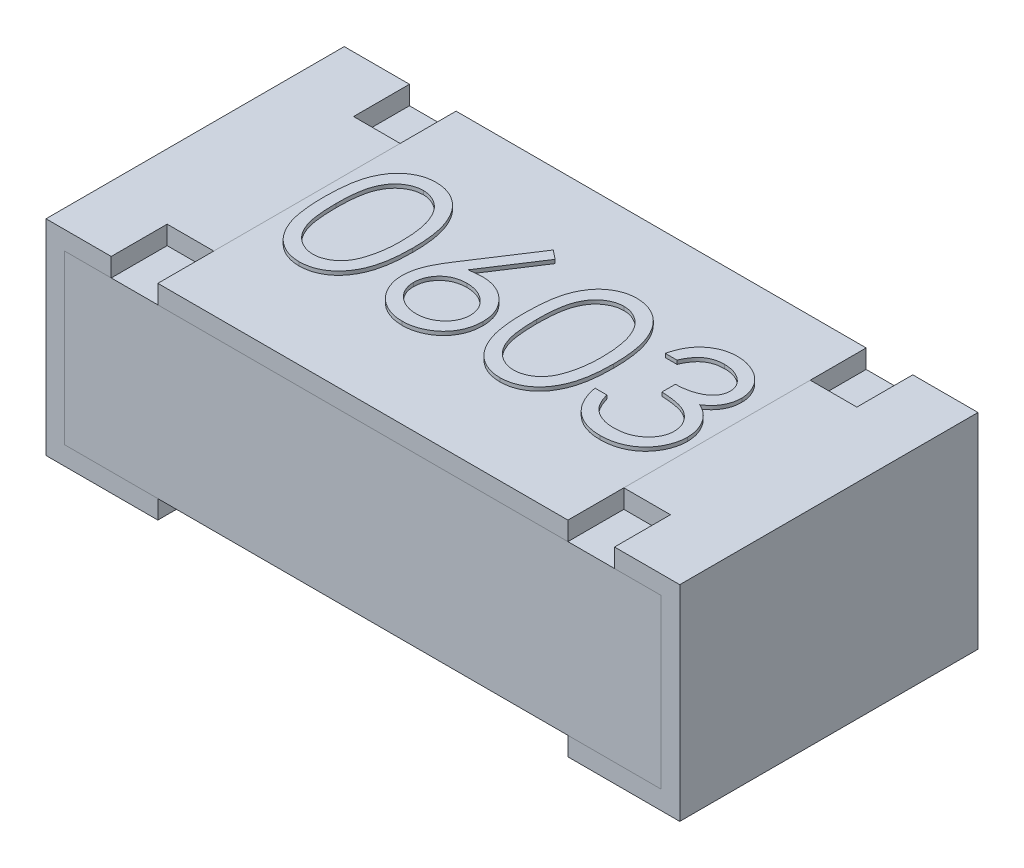
from build123d import *

# Parameters (mm, degrees)
CROQUIS1_W          = 1.6
CROQUIS1_H          = 0.8
EXTRUIR1_DEPTH      = 0.5
CROQUIS2_W          = 1.6
CROQUIS2_H          = 0.05
EXTRUIR2_DEPTH      = 2.236931688
CROQUIS4_W          = 0.8
CROQUIS4_H          = 0.05
EXTRUIR3_DEPTH      = 1.1
CROQUIS5_W          = 0.125
CROQUIS5_H          = 0.15
EXTRUIR4_DEPTH      = 0.05
BOSS_EXTRUDE1_DEPTH = 0.01


with BuildPart() as part:
    # Croquis1 → Extruir1 (new body)
    with BuildSketch(Plane(origin=(0, 0, 0), x_dir=(1, 0, 0), z_dir=(0, 1, 0))):
        Rectangle(CROQUIS1_W, CROQUIS1_H)
    extrude(amount=EXTRUIR1_DEPTH)

    # Croquis2 → Extruir2 (cut, through all)
    with BuildSketch(Plane.XY.offset(0.4)):
        with Locations((0, 0.025)):
            Rectangle(CROQUIS2_W, CROQUIS2_H)
    extrude(amount=-EXTRUIR2_DEPTH, mode=Mode.SUBTRACT)


with BuildPart() as body_2:
    # Barrer1: sweep along a path in Croquis3
    with BuildLine(Plane.XY.offset(0.4)) as barrer1_path:
        Line((-0.55, 0.55), (-0.85, 0.55))
        Line((-0.85, 0.55), (-0.85, 0))
        Line((-0.85, 0), (-0.55, 0))
    # Croquis3D1 → Barrer1 (sweep)
    with BuildSketch(Plane(origin=(-0.55, 0.55, 0.4), x_dir=(0, -0.06237828615518069, -0.9980525784828886), z_dir=(1, 0, 0))):
        Polygon((0, 0), (0.798442063, 0.049902629), (0.801560977, 0), (0.003118914, -0.049902629), align=None)
    sweep(path=barrer1_path.line, transition=Transition.RIGHT)


with BuildPart() as body_3:
    # Simetría1: mirrored copy
    add(body_2.part.mirror(Plane(origin=(0, 0.5, 0.4), x_dir=(0, 0, 1), z_dir=(1, 0, 0))))


with BuildPart() as body_4:
    # Croquis4 → Extruir3 (new body)
    with BuildSketch(Plane(origin=(-0.55, 0, 0), x_dir=(0, 0, -1), z_dir=(1, 0, 0))):
        with Locations((0, 0.525)):
            Rectangle(CROQUIS4_W, CROQUIS4_H)
    extrude(amount=EXTRUIR3_DEPTH)

    # Sketch1 → Boss-Extrude1 (add)
    with BuildSketch(Plane(origin=(0, 0.55, 0), x_dir=(1, 0, 0), z_dir=(0, 1, 0))):
        with BuildLine():
            add(Edge.make_bspline(
                [(-0.517880419, 0.013609611), (-0.517847617, 0.019219349), (-0.517783899, 0.030116348), (-0.517075057, 0.045994812), (-0.515897523, 0.060890841), (-0.514283786, 0.074805147), (-0.512319988, 0.087741324), (-0.509698439, 0.0996648), (-0.506717159, 0.11063076), (-0.503261914, 0.120674965), (-0.499363135, 0.129932735), (-0.495119709, 0.138575256), (-0.49036323, 0.146589449), (-0.485365539, 0.154103228), (-0.479924331, 0.160993597), (-0.474194452, 0.167357864), (-0.467952265, 0.173048939), (-0.461409964, 0.178233569), (-0.454508318, 0.182778516), (-0.447444051, 0.18678179), (-0.44016854, 0.190201777), (-0.432661922, 0.19289082), (-0.424991666, 0.195111905), (-0.41713096, 0.1966308), (-0.409066823, 0.19758649), (-0.40362368, 0.197677857), (-0.400863192, 0.197724194)],
                knots=[0, 0, 0, 0, 1.646270934, 3.197905019, 4.663502075, 6.030701355, 7.308322542, 8.50163776, 9.611534131, 10.641858119, 11.616356847, 12.558055219, 13.465016945, 14.349605745, 15.204443733, 16.039544428, 16.859896111, 17.680448484, 18.487036065, 19.28249412, 20.06191084, 20.843045899, 21.620316918, 22.403196591, 23.190181807, 24, 24, 24, 24], degree=3))
            add(Edge.make_bspline(
                [(-0.400863192, 0.197724194), (-0.398079644, 0.197675412), (-0.392544043, 0.197578401), (-0.384360005, 0.196646007), (-0.376365037, 0.195098895), (-0.368593223, 0.192906797), (-0.360980725, 0.19018723), (-0.353587084, 0.186778518), (-0.346366376, 0.182810631), (-0.339433347, 0.178148243), (-0.332711886, 0.172950016), (-0.326367089, 0.167073749), (-0.320398381, 0.160578777), (-0.31473085, 0.153534591), (-0.30952529, 0.145806082), (-0.304567947, 0.137527671), (-0.300130744, 0.128554585), (-0.295857276, 0.119036538), (-0.292168577, 0.108710172), (-0.288841953, 0.097633696), (-0.286154056, 0.085676277), (-0.283915129, 0.072900653), (-0.282180639, 0.059259904), (-0.280917375, 0.044783273), (-0.280250066, 0.029461234), (-0.280124396, 0.018985449), (-0.280059906, 0.013609611)],
                knots=[0, 0, 0, 0, 0.810914788, 1.612654377, 2.396697861, 3.181598691, 3.963628158, 4.749916497, 5.551656086, 6.361998678, 7.18212741, 8.025565596, 8.878627764, 9.750805457, 10.657531673, 11.591944965, 12.560506719, 13.57287815, 14.630710178, 15.753379473, 16.941251878, 18.199788006, 19.531962791, 20.947069417, 22.433333509, 24, 24, 24, 24], degree=3))
            add(Edge.make_bspline(
                [(-0.280059906, 0.013609611), (-0.280125065, 0.00825722), (-0.280252024, -0.002171695), (-0.280909894, -0.017424793), (-0.282205757, -0.031824597), (-0.283826756, -0.045405644), (-0.286071852, -0.058111405), (-0.288832369, -0.06998585), (-0.291897401, -0.081080257), (-0.295680881, -0.091303739), (-0.299821952, -0.100798911), (-0.304327471, -0.109665626), (-0.309154454, -0.117982255), (-0.314413329, -0.12568223), (-0.32001867, -0.132820095), (-0.326090449, -0.139269858), (-0.332457507, -0.145186925), (-0.339198749, -0.150452088), (-0.346239904, -0.155060568), (-0.353435812, -0.159181953), (-0.36091415, -0.162505223), (-0.368505445, -0.165358727), (-0.376318282, -0.167538772), (-0.384342921, -0.169046157), (-0.392538545, -0.170103342), (-0.398078701, -0.17018399), (-0.400863192, -0.170224524)],
                knots=[0, 0, 0, 0, 1.561518951, 3.042555995, 4.452378317, 5.7783523, 7.031515105, 8.214008947, 9.334062868, 10.386615937, 11.391082383, 12.354592575, 13.286541444, 14.194233754, 15.072674879, 15.931287219, 16.775624067, 17.606195743, 18.42308326, 19.229000347, 20.022332153, 20.807536673, 21.593273796, 22.3848459, 23.188221202, 24, 24, 24, 24], degree=3))
            add(Edge.make_bspline(
                [(-0.400863192, -0.170224524), (-0.403623603, -0.170177889), (-0.409066596, -0.170085932), (-0.417131838, -0.169134559), (-0.424960083, -0.167605009), (-0.432589958, -0.165463348), (-0.440060609, -0.162841865), (-0.447270238, -0.159426496), (-0.454299006, -0.15549309), (-0.461128162, -0.151013547), (-0.467629378, -0.145881379), (-0.473839239, -0.14020495), (-0.479601741, -0.133842609), (-0.48496515, -0.126894817), (-0.490062559, -0.119425493), (-0.494751496, -0.111332655), (-0.499088582, -0.102648394), (-0.503052931, -0.093316603), (-0.506567797, -0.08320111), (-0.509672568, -0.072186193), (-0.512123984, -0.060174629), (-0.514222279, -0.047262892), (-0.515914718, -0.033395499), (-0.51707015, -0.018564921), (-0.517784282, -0.0027804), (-0.517847789, 0.008046577), (-0.517880419, 0.013609611)],
                knots=[0, 0, 0, 0, 0.810891512, 1.598919785, 2.382837074, 3.152667961, 3.926044502, 4.706494248, 5.493654104, 6.291793342, 7.103789334, 7.925228297, 8.761435821, 9.622817696, 10.50288917, 11.416980706, 12.369136599, 13.353924996, 14.394355917, 15.514179734, 16.714354668, 17.994756427, 19.357759367, 20.818452758, 22.365282078, 24, 24, 24, 24], degree=3))
        make_face()
        with BuildLine():
            add(Edge.make_bspline(
                [(-0.486470163, 0.013749835), (-0.486458218, 0.009074965), (-0.486435036, 1.961e-06), (-0.485829416, -0.013182366), (-0.485004393, -0.025479398), (-0.483940263, -0.036904752), (-0.482359968, -0.047419753), (-0.480589289, -0.057096722), (-0.47843448, -0.065884445), (-0.475884978, -0.073843226), (-0.472981069, -0.081108133), (-0.469810482, -0.087868255), (-0.46640441, -0.094203448), (-0.462592495, -0.100056809), (-0.458440989, -0.105447426), (-0.454043663, -0.110470709), (-0.449236404, -0.114950407), (-0.44258603, -0.120323093), (-0.433806383, -0.125875006), (-0.422744337, -0.130709615), (-0.411377492, -0.133747861), (-0.403662367, -0.134134236), (-0.399811509, -0.134327088)],
                knots=[0, 0, 0, 0, 1.459021318, 2.831673884, 4.118529203, 5.306027144, 6.411944654, 7.436330062, 8.375795394, 9.233974572, 10.042671642, 10.816086306, 11.563610507, 12.285937304, 12.993564865, 13.685989202, 14.367179055, 15.041617293, 16.353048772, 17.594441528, 18.799311195, 20, 20, 20, 20], degree=3))
            add(Edge.make_bspline(
                [(-0.399811509, -0.134327088), (-0.395935742, -0.13416731), (-0.38819221, -0.133848084), (-0.37687883, -0.13076821), (-0.365895803, -0.126121256), (-0.357288609, -0.120626506), (-0.350740355, -0.115393673), (-0.346048656, -0.110932208), (-0.341742451, -0.105936621), (-0.337658243, -0.100546692), (-0.333912336, -0.094659443), (-0.330506022, -0.088303186), (-0.327397687, -0.081460268), (-0.325626783, -0.076683294), (-0.324721365, -0.07424095)],
                knots=[0, 0, 0, 0, 1.353760809, 2.704726607, 4.075137775, 5.516104923, 6.260822281, 7.007110065, 7.778089737, 8.566572457, 9.372053459, 10.217411131, 11.088608312, 12, 12, 12, 12], degree=3))
            add(Edge.make_bspline(
                [(-0.324721365, -0.07424095), (-0.323666188, -0.071117976), (-0.321523727, -0.064777), (-0.318762549, -0.054940635), (-0.316588009, -0.044620358), (-0.314631673, -0.033877847), (-0.313296367, -0.022633877), (-0.312221586, -0.010923238), (-0.311588517, 0.001262898), (-0.311510042, 0.009542397), (-0.311470163, 0.013749835)],
                knots=[0, 0, 0, 0, 0.884706709, 1.796334032, 2.740027952, 3.714592787, 4.726048262, 5.777819803, 6.87074269, 8, 8, 8, 8], degree=3))
            add(Edge.make_bspline(
                [(-0.311470163, 0.013749835), (-0.311525182, 0.017956592), (-0.311632811, 0.026185909), (-0.312044209, 0.038237727), (-0.313106567, 0.049684503), (-0.314286479, 0.06057555), (-0.316026201, 0.07085058), (-0.317901981, 0.080595611), (-0.320422103, 0.089689913), (-0.32311408, 0.098275871), (-0.32619512, 0.106255937), (-0.329586693, 0.113667316), (-0.333208869, 0.120545788), (-0.337143093, 0.126872482), (-0.341342661, 0.132675736), (-0.345918416, 0.137839196), (-0.350688854, 0.142522893), (-0.357370572, 0.14786915), (-0.366118001, 0.153320319), (-0.377002566, 0.158336895), (-0.38832963, 0.161217724), (-0.395986976, 0.161623893), (-0.399811509, 0.161826758)],
                knots=[0, 0, 0, 0, 1.31362396, 2.569729283, 3.763502607, 4.902122613, 5.988968491, 7.01645872, 7.998833611, 8.933434873, 9.825090667, 10.667526885, 11.477055099, 12.250526234, 12.991942729, 13.710640831, 14.402115721, 15.076753259, 16.378508321, 17.609869233, 18.806226677, 20, 20, 20, 20], degree=3))
            add(Edge.make_bspline(
                [(-0.399811509, 0.161826758), (-0.403682568, 0.161623613), (-0.411431739, 0.161216954), (-0.422876534, 0.158347629), (-0.433846969, 0.153346332), (-0.442571267, 0.147851095), (-0.449257646, 0.142617264), (-0.453965915, 0.138078618), (-0.458380532, 0.133113993), (-0.462447302, 0.127673801), (-0.46625623, 0.121827264), (-0.469754332, 0.115528388), (-0.472906065, 0.108745252), (-0.475814518, 0.101483608), (-0.478371797, 0.093525514), (-0.480481193, 0.084748614), (-0.482429899, 0.075102425), (-0.483809426, 0.064530474), (-0.485035801, 0.053102259), (-0.485823936, 0.040774527), (-0.486437062, 0.027568089), (-0.486458908, 0.018448173), (-0.486470163, 0.013749835)],
                knots=[0, 0, 0, 0, 1.207732386, 2.417664972, 3.655092373, 4.956220595, 5.625982001, 6.301752483, 6.994047911, 7.697131622, 8.419323945, 9.170223765, 9.943494443, 10.752040957, 11.610060368, 12.549350801, 13.567764191, 14.679664412, 15.874934091, 17.154273443, 18.533957287, 20, 20, 20, 20], degree=3))
        make_face(mode=Mode.SUBTRACT)
        with BuildLine():
            Line((-0.087111189, 0.197724194), (-0.062922487, 0.178723793))
            Line((-0.062922487, 0.178723793), (-0.155400451, 0.037307527))
            add(Edge.make_bspline(
                [(-0.155400451, 0.037307527), (-0.149243424, 0.038288913), (-0.137233445, 0.040203218), (-0.125076855, 0.040519012), (-0.119152455, 0.040672912)],
                knots=[0, 0, 0, 0, 1.025318673, 2, 2, 2, 2], degree=3))
            add(Edge.make_bspline(
                [(-0.119152455, 0.040672912), (-0.115595205, 0.040577301), (-0.108592865, 0.040389093), (-0.098312185, 0.038940708), (-0.088433291, 0.036658197), (-0.07899713, 0.033330971), (-0.069969832, 0.029080736), (-0.061299592, 0.023986849), (-0.053149391, 0.017786281), (-0.045414273, 0.010859785), (-0.038391563, 0.003188087), (-0.032173958, -0.004952047), (-0.026951279, -0.013552135), (-0.022713886, -0.022607822), (-0.019423399, -0.032105148), (-0.017024634, -0.042031962), (-0.015606675, -0.052395109), (-0.015414126, -0.059442926), (-0.015316317, -0.063023002)],
                knots=[0, 0, 0, 0, 1.04369286, 2.054478336, 3.041073146, 4.015093852, 4.984733326, 5.965804835, 6.960378782, 7.985147595, 9.009457201, 10.008161701, 10.986880575, 11.956520048, 12.937015923, 13.931873656, 14.949455224, 16, 16, 16, 16], degree=3))
            add(Edge.make_bspline(
                [(-0.015316317, -0.063023002), (-0.015458627, -0.067920972), (-0.015738661, -0.077559019), (-0.01852904, -0.091596689), (-0.022865005, -0.104969941), (-0.029062758, -0.117465258), (-0.036760996, -0.129065515), (-0.046148755, -0.139344061), (-0.056893104, -0.148511065), (-0.069041784, -0.156176727), (-0.08211608, -0.162437032), (-0.09585128, -0.166933556), (-0.110113995, -0.169701903), (-0.119794455, -0.170048964), (-0.124691317, -0.170224524)],
                knots=[0, 0, 0, 0, 1.031375318, 2.029502543, 3.004789286, 3.987476834, 4.960371455, 5.9300674, 6.912260825, 7.929083631, 8.949397511, 9.960523116, 10.96833055, 12, 12, 12, 12], degree=3))
            add(Edge.make_bspline(
                [(-0.124691317, -0.170224524), (-0.129400987, -0.170071704), (-0.138730019, -0.169768993), (-0.152453298, -0.167072399), (-0.1656396, -0.162701689), (-0.178196538, -0.156680261), (-0.189828599, -0.149074473), (-0.200235163, -0.139918245), (-0.20936434, -0.129407298), (-0.216961802, -0.117543263), (-0.222987676, -0.104794268), (-0.227506668, -0.091500552), (-0.230146292, -0.077710554), (-0.230515148, -0.06836244), (-0.230700932, -0.063654011)],
                knots=[0, 0, 0, 0, 1.012016664, 2.004627821, 2.994792927, 3.992885782, 4.990978636, 5.973936114, 6.964471063, 7.975201453, 8.993600317, 9.990122807, 10.98767138, 12, 12, 12, 12], degree=3))
            add(Edge.make_bspline(
                [(-0.230700932, -0.063654011), (-0.230582788, -0.060049553), (-0.230341559, -0.052689938), (-0.22865722, -0.041543535), (-0.225950741, -0.030138427), (-0.222919716, -0.020463007), (-0.219717155, -0.012536855), (-0.217051901, -0.006146506), (-0.213734501, 0.000429601), (-0.210197163, 0.007416965), (-0.206121476, 0.014635508), (-0.201689911, 0.022205875), (-0.196779946, 0.030007668), (-0.19333793, 0.035302087), (-0.191578336, 0.038008649)],
                knots=[0, 0, 0, 0, 1.173818275, 2.396712641, 3.66331629, 4.989737886, 5.693666774, 6.447286557, 7.243889047, 8.091586357, 8.998013824, 9.943181721, 10.948533338, 12, 12, 12, 12], degree=3))
            Line((-0.191578336, 0.038008649), (-0.087111189, 0.197724194))
        make_face()
        with BuildLine():
            add(Edge.make_bspline(
                [(-0.125742999, 0.004775476), (-0.128409224, 0.004697672), (-0.133617135, 0.004545697), (-0.141257876, 0.003663172), (-0.148489201, 0.002001265), (-0.155406915, -0.000115368), (-0.161881685, -0.003025674), (-0.167960569, -0.006560854), (-0.173667074, -0.010722972), (-0.178941429, -0.015453063), (-0.183723396, -0.020631866), (-0.187841509, -0.026178818), (-0.191393749, -0.031960239), (-0.194281931, -0.038024433), (-0.196530938, -0.044369083), (-0.198157763, -0.050965008), (-0.199063139, -0.057856438), (-0.199213762, -0.062529689), (-0.199290676, -0.064916031)],
                knots=[0, 0, 0, 0, 1.129588631, 2.206414736, 3.251139165, 4.268635594, 5.265702196, 6.250456724, 7.242448911, 8.251968645, 9.246821453, 10.222880186, 11.173611482, 12.116736599, 13.062300278, 14.020270554, 14.989073742, 16, 16, 16, 16], degree=3))
            add(Edge.make_bspline(
                [(-0.199290676, -0.064916031), (-0.19922804, -0.067281028), (-0.199105219, -0.071918437), (-0.197989987, -0.078752355), (-0.196286479, -0.085328846), (-0.19375244, -0.091614006), (-0.190729751, -0.097703638), (-0.186739218, -0.103377166), (-0.18231754, -0.108979174), (-0.177032146, -0.114079321), (-0.17135981, -0.118824983), (-0.16529969, -0.122973008), (-0.158983694, -0.126521626), (-0.152326552, -0.129302736), (-0.145422713, -0.131585164), (-0.138214658, -0.133191312), (-0.130697372, -0.134099365), (-0.125605179, -0.134250184), (-0.123008624, -0.134327088)],
                knots=[0, 0, 0, 0, 0.989467248, 1.94019797, 2.891935182, 3.827694429, 4.772920941, 5.730924762, 6.725747692, 7.756678648, 8.79901574, 9.819492441, 10.826891316, 11.826466727, 12.835195252, 13.867842842, 14.912794438, 16, 16, 16, 16], degree=3))
            add(Edge.make_bspline(
                [(-0.123008624, -0.134327088), (-0.120412075, -0.134250178), (-0.115319889, -0.134099347), (-0.107802543, -0.13319138), (-0.100594711, -0.131584915), (-0.09369006, -0.129303638), (-0.087035917, -0.126518277), (-0.080725445, -0.122995085), (-0.074722636, -0.118799473), (-0.069046576, -0.114087431), (-0.063783182, -0.108950145), (-0.059255454, -0.103427173), (-0.055387131, -0.097657784), (-0.052243712, -0.091637995), (-0.049737583, -0.085325046), (-0.048025436, -0.078753374), (-0.046912507, -0.071918171), (-0.046789371, -0.067280938), (-0.046726573, -0.064916031)],
                knots=[0, 0, 0, 0, 1.087397944, 2.132534446, 3.165364764, 4.174271784, 5.174024072, 6.181601208, 7.194203697, 8.236725232, 9.267838612, 10.269026844, 11.221737037, 12.171628256, 13.107553087, 14.05945871, 15.010357665, 16, 16, 16, 16], degree=3))
            add(Edge.make_bspline(
                [(-0.046726573, -0.064916031), (-0.046781602, -0.062526575), (-0.046889607, -0.057836852), (-0.048111202, -0.05096809), (-0.049805439, -0.04433557), (-0.052363742, -0.037980975), (-0.055687397, -0.031929382), (-0.059735738, -0.026150222), (-0.064418995, -0.020599187), (-0.069828749, -0.015442906), (-0.075717772, -0.010728199), (-0.08197933, -0.006566243), (-0.088530128, -0.003053745), (-0.095363522, -0.000123035), (-0.10255781, 0.001991912), (-0.109996844, 0.003657237), (-0.117775769, 0.004543438), (-0.123053429, 0.004697145), (-0.125742999, 0.004775476)],
                knots=[0, 0, 0, 0, 0.978206639, 1.919901502, 2.851605144, 3.780102724, 4.718870031, 5.675451981, 6.667674623, 7.690630536, 8.733308323, 9.756129687, 10.767539656, 11.776269907, 12.797430371, 13.836405707, 14.897401972, 16, 16, 16, 16], degree=3))
        make_face(mode=Mode.SUBTRACT)
        with BuildLine():
            add(Edge.make_bspline(
                [(0.020581119, 0.013609611), (0.020613921, 0.019219349), (0.020677639, 0.030116348), (0.021386481, 0.045994812), (0.022564015, 0.060890841), (0.024177753, 0.074805147), (0.026141551, 0.087741324), (0.028763099, 0.0996648), (0.03174438, 0.11063076), (0.035199624, 0.120674965), (0.039098403, 0.129932735), (0.043341829, 0.138575256), (0.048098309, 0.146589449), (0.053096, 0.154103228), (0.058537207, 0.160993597), (0.064267086, 0.167357864), (0.070509274, 0.173048939), (0.077051574, 0.178233569), (0.083953221, 0.182778516), (0.091017488, 0.18678179), (0.098292998, 0.190201777), (0.105799616, 0.19289082), (0.113469872, 0.195111905), (0.121330579, 0.1966308), (0.129394715, 0.19758649), (0.134837859, 0.197677857), (0.137598347, 0.197724194)],
                knots=[0, 0, 0, 0, 1.646270934, 3.197905019, 4.663502075, 6.030701355, 7.308322542, 8.50163776, 9.611534131, 10.641858119, 11.616356847, 12.558055219, 13.465016945, 14.349605745, 15.204443733, 16.039544428, 16.859896111, 17.680448484, 18.487036065, 19.28249412, 20.06191084, 20.843045899, 21.620316918, 22.403196591, 23.190181807, 24, 24, 24, 24], degree=3))
            add(Edge.make_bspline(
                [(0.137598347, 0.197724194), (0.140381895, 0.197675412), (0.145917495, 0.197578401), (0.154101533, 0.196646007), (0.162096501, 0.195098895), (0.169868315, 0.192906797), (0.177480814, 0.19018723), (0.184874454, 0.186778518), (0.192095163, 0.182810631), (0.199028191, 0.178148243), (0.205749653, 0.172950016), (0.212094449, 0.167073749), (0.218063158, 0.160578777), (0.223730688, 0.153534591), (0.228936248, 0.145806082), (0.233893591, 0.137527671), (0.238330795, 0.128554585), (0.242604262, 0.119036538), (0.246292961, 0.108710172), (0.249619586, 0.097633696), (0.252307482, 0.085676277), (0.25454641, 0.072900653), (0.256280899, 0.059259904), (0.257544163, 0.044783273), (0.258211472, 0.029461234), (0.258337142, 0.018985449), (0.258401632, 0.013609611)],
                knots=[0, 0, 0, 0, 0.810914788, 1.612654377, 2.396697861, 3.181598691, 3.963628158, 4.749916497, 5.551656086, 6.361998678, 7.18212741, 8.025565596, 8.878627764, 9.750805457, 10.657531673, 11.591944965, 12.560506719, 13.57287815, 14.630710178, 15.753379473, 16.941251878, 18.199788006, 19.531962791, 20.947069417, 22.433333509, 24, 24, 24, 24], degree=3))
            add(Edge.make_bspline(
                [(0.258401632, 0.013609611), (0.258336474, 0.00825722), (0.258209515, -0.002171695), (0.257551644, -0.017424793), (0.256255781, -0.031824597), (0.254634782, -0.045405644), (0.252389686, -0.058111405), (0.249629169, -0.06998585), (0.246564137, -0.081080257), (0.242780658, -0.091303739), (0.238639587, -0.100798911), (0.234134067, -0.109665626), (0.229307084, -0.117982255), (0.22404821, -0.12568223), (0.218442869, -0.132820095), (0.21237109, -0.139269858), (0.206004031, -0.145186925), (0.19926279, -0.150452088), (0.192221635, -0.155060568), (0.185025727, -0.159181953), (0.177547388, -0.162505223), (0.169956093, -0.165358727), (0.162143257, -0.167538772), (0.154118618, -0.169046157), (0.145922994, -0.170103342), (0.140382837, -0.17018399), (0.137598347, -0.170224524)],
                knots=[0, 0, 0, 0, 1.561518951, 3.042555995, 4.452378317, 5.7783523, 7.031515105, 8.214008947, 9.334062868, 10.386615937, 11.391082383, 12.354592575, 13.286541444, 14.194233754, 15.072674879, 15.931287219, 16.775624067, 17.606195743, 18.42308326, 19.229000347, 20.022332153, 20.807536673, 21.593273796, 22.3848459, 23.188221202, 24, 24, 24, 24], degree=3))
            add(Edge.make_bspline(
                [(0.137598347, -0.170224524), (0.134837935, -0.170177889), (0.129394943, -0.170085932), (0.1213297, -0.169134559), (0.113501456, -0.167605009), (0.105871581, -0.165463348), (0.098400929, -0.162841865), (0.0911913, -0.159426496), (0.084162532, -0.15549309), (0.077333376, -0.151013547), (0.07083216, -0.145881379), (0.0646223, -0.14020495), (0.058859798, -0.133842609), (0.053496388, -0.126894817), (0.048398979, -0.119425493), (0.043710042, -0.111332655), (0.039372957, -0.102648394), (0.035408608, -0.093316603), (0.031893741, -0.08320111), (0.028788971, -0.072186193), (0.026337555, -0.060174629), (0.024239259, -0.047262892), (0.022546821, -0.033395499), (0.021391388, -0.018564921), (0.020677257, -0.0027804), (0.02061375, 0.008046577), (0.020581119, 0.013609611)],
                knots=[0, 0, 0, 0, 0.810891512, 1.598919785, 2.382837074, 3.152667961, 3.926044502, 4.706494248, 5.493654104, 6.291793342, 7.103789334, 7.925228297, 8.761435821, 9.622817696, 10.50288917, 11.416980706, 12.369136599, 13.353924996, 14.394355917, 15.514179734, 16.714354668, 17.994756427, 19.357759367, 20.818452758, 22.365282078, 24, 24, 24, 24], degree=3))
        make_face()
        with BuildLine():
            add(Edge.make_bspline(
                [(0.051991376, 0.013749835), (0.05200332, 0.009074965), (0.052026503, 1.961e-06), (0.052632123, -0.013182366), (0.053457146, -0.025479398), (0.054521276, -0.036904752), (0.05610157, -0.047419753), (0.057872249, -0.057096722), (0.060027058, -0.065884445), (0.06257656, -0.073843226), (0.06548047, -0.081108133), (0.068651056, -0.087868255), (0.072057128, -0.094203448), (0.075869043, -0.100056809), (0.08002055, -0.105447426), (0.084417876, -0.110470709), (0.089225134, -0.114950407), (0.095875508, -0.120323093), (0.104655156, -0.125875006), (0.115717201, -0.130709615), (0.127084046, -0.133747861), (0.134799171, -0.134134236), (0.138650029, -0.134327088)],
                knots=[0, 0, 0, 0, 1.459021318, 2.831673884, 4.118529203, 5.306027144, 6.411944654, 7.436330062, 8.375795394, 9.233974572, 10.042671642, 10.816086306, 11.563610507, 12.285937304, 12.993564865, 13.685989202, 14.367179055, 15.041617293, 16.353048772, 17.594441528, 18.799311195, 20, 20, 20, 20], degree=3))
            add(Edge.make_bspline(
                [(0.138650029, -0.134327088), (0.142525797, -0.13416731), (0.150269329, -0.133848084), (0.161582708, -0.13076821), (0.172565735, -0.126121256), (0.181172929, -0.120626506), (0.187721184, -0.115393673), (0.192412883, -0.110932208), (0.196719088, -0.105936621), (0.200803295, -0.100546692), (0.204549203, -0.094659443), (0.207955516, -0.088303186), (0.211063851, -0.081460268), (0.212834756, -0.076683294), (0.213740174, -0.07424095)],
                knots=[0, 0, 0, 0, 1.353760809, 2.704726607, 4.075137775, 5.516104923, 6.260822281, 7.007110065, 7.778089737, 8.566572457, 9.372053459, 10.217411131, 11.088608312, 12, 12, 12, 12], degree=3))
            add(Edge.make_bspline(
                [(0.213740174, -0.07424095), (0.21479535, -0.071117976), (0.216937812, -0.064777), (0.219698989, -0.054940635), (0.221873529, -0.044620358), (0.223829866, -0.033877847), (0.225165171, -0.022633877), (0.226239953, -0.010923238), (0.226873021, 0.001262898), (0.226951496, 0.009542397), (0.226991376, 0.013749835)],
                knots=[0, 0, 0, 0, 0.884706709, 1.796334032, 2.740027952, 3.714592787, 4.726048262, 5.777819803, 6.87074269, 8, 8, 8, 8], degree=3))
            add(Edge.make_bspline(
                [(0.226991376, 0.013749835), (0.226936357, 0.017956592), (0.226828728, 0.026185909), (0.226417329, 0.038237727), (0.225354972, 0.049684503), (0.22417506, 0.06057555), (0.222435338, 0.07085058), (0.220559557, 0.080595611), (0.218039436, 0.089689913), (0.215347458, 0.098275871), (0.212266419, 0.106255937), (0.208874845, 0.113667316), (0.205252669, 0.120545788), (0.201318445, 0.126872482), (0.197118877, 0.132675736), (0.192543122, 0.137839196), (0.187772685, 0.142522893), (0.181090966, 0.14786915), (0.172343537, 0.153320319), (0.161458973, 0.158336895), (0.150131908, 0.161217724), (0.142474563, 0.161623893), (0.138650029, 0.161826758)],
                knots=[0, 0, 0, 0, 1.31362396, 2.569729283, 3.763502607, 4.902122613, 5.988968491, 7.01645872, 7.998833611, 8.933434873, 9.825090667, 10.667526885, 11.477055099, 12.250526234, 12.991942729, 13.710640831, 14.402115721, 15.076753259, 16.378508321, 17.609869233, 18.806226677, 20, 20, 20, 20], degree=3))
            add(Edge.make_bspline(
                [(0.138650029, 0.161826758), (0.13477897, 0.161623613), (0.1270298, 0.161216954), (0.115585004, 0.158347629), (0.104614569, 0.153346332), (0.095890272, 0.147851095), (0.089203893, 0.142617264), (0.084495624, 0.138078618), (0.080081006, 0.133113993), (0.076014236, 0.127673801), (0.072205308, 0.121827264), (0.068707207, 0.115528388), (0.065555474, 0.108745252), (0.06264702, 0.101483608), (0.060089741, 0.093525514), (0.057980345, 0.084748614), (0.05603164, 0.075102425), (0.054652113, 0.064530474), (0.053425737, 0.053102259), (0.052637602, 0.040774527), (0.052024477, 0.027568089), (0.05200263, 0.018448173), (0.051991376, 0.013749835)],
                knots=[0, 0, 0, 0, 1.207732386, 2.417664972, 3.655092373, 4.956220595, 5.625982001, 6.301752483, 6.994047911, 7.697131622, 8.419323945, 9.170223765, 9.943494443, 10.752040957, 11.610060368, 12.549350801, 13.567764191, 14.679664412, 15.874934091, 17.154273443, 18.533957287, 20, 20, 20, 20], degree=3))
        make_face(mode=Mode.SUBTRACT)
        with BuildLine():
            Line((0.334683683, 0.107980604), (0.303273427, 0.107980604))
            add(Edge.make_bspline(
                [(0.303273427, 0.107980604), (0.304124382, 0.111503853), (0.305787929, 0.118391515), (0.309257687, 0.128232241), (0.313037612, 0.137544593), (0.317576523, 0.146154201), (0.322527398, 0.154234091), (0.32819967, 0.161601003), (0.334331643, 0.1684423), (0.341114138, 0.174513624), (0.348227004, 0.180011396), (0.355770466, 0.184698902), (0.363592755, 0.188731318), (0.371748068, 0.192053341), (0.380260686, 0.194555893), (0.389053648, 0.196371574), (0.398149998, 0.197550685), (0.404324757, 0.197665761), (0.407460126, 0.197724194)],
                knots=[0, 0, 0, 0, 1.162005537, 2.271625781, 3.343758855, 4.383309926, 5.390229558, 6.379919256, 7.361854164, 8.333198761, 9.295911338, 10.242430842, 11.177959212, 12.116337295, 13.062827104, 14.020064771, 14.994644689, 16, 16, 16, 16], degree=3))
            add(Edge.make_bspline(
                [(0.407460126, 0.197724194), (0.4120284, 0.197586271), (0.421065301, 0.197313433), (0.434341606, 0.19482199), (0.447144287, 0.190879476), (0.459333212, 0.185432104), (0.470655056, 0.178713372), (0.480728674, 0.170716899), (0.489417525, 0.161596969), (0.496706963, 0.151523712), (0.502414463, 0.140758161), (0.5066231, 0.129678145), (0.509185268, 0.118309948), (0.509517324, 0.11063422), (0.509683683, 0.106788697)],
                knots=[0, 0, 0, 0, 1.083050992, 2.142477498, 3.193116406, 4.255571735, 5.30263384, 6.308962982, 7.297363603, 8.282367274, 9.249857812, 10.179914175, 11.08814088, 12, 12, 12, 12], degree=3))
            add(Edge.make_bspline(
                [(0.509683683, 0.106788697), (0.509567324, 0.103088018), (0.509339627, 0.095846362), (0.507406257, 0.085274212), (0.504152631, 0.075310052), (0.499645654, 0.065911936), (0.493811499, 0.057139452), (0.48674423, 0.048972863), (0.478393963, 0.041375947), (0.47206607, 0.037024), (0.468808283, 0.034783489)],
                knots=[0, 0, 0, 0, 1.024540389, 2.004866551, 2.965041327, 3.920577974, 4.882998113, 5.874504559, 6.905732034, 8, 8, 8, 8], degree=3))
            add(Edge.make_bspline(
                [(0.468808283, 0.034783489), (0.472531458, 0.032985672), (0.479908146, 0.029423676), (0.489963198, 0.0224381), (0.499090986, 0.014372465), (0.504181358, 0.0080782), (0.506738972, 0.0049157)],
                knots=[0, 0, 0, 0, 1.015518401, 2.012035669, 3.001164323, 4, 4, 4, 4], degree=3))
            add(Edge.make_bspline(
                [(0.506738972, 0.0049157), (0.508423106, 0.002609925), (0.511763796, -0.001963867), (0.515887349, -0.009317509), (0.51962826, -0.016752658), (0.522543282, -0.024468599), (0.524800669, -0.0323759), (0.526414272, -0.04048814), (0.527416686, -0.048811942), (0.527560241, -0.05444319), (0.527632401, -0.057273803)],
                knots=[0, 0, 0, 0, 1.025084078, 2.033381695, 3.024893161, 4.013698104, 4.991890475, 5.976764909, 6.982997093, 8, 8, 8, 8], degree=3))
            add(Edge.make_bspline(
                [(0.527632401, -0.057273803), (0.52745295, -0.062174775), (0.527094892, -0.071953655), (0.523894484, -0.086401127), (0.51893316, -0.100523678), (0.511887467, -0.114031162), (0.503300716, -0.1266692), (0.493084983, -0.137976831), (0.481356342, -0.147696691), (0.468275778, -0.155817714), (0.454104065, -0.162309506), (0.438946505, -0.16681525), (0.4230215, -0.16974985), (0.41210077, -0.170064537), (0.406548667, -0.170224524)],
                knots=[0, 0, 0, 0, 0.955779014, 1.907060117, 2.875433937, 3.871313158, 4.872415639, 5.851225146, 6.836215519, 7.83643374, 8.849228613, 9.86973379, 10.916971861, 12, 12, 12, 12], degree=3))
            add(Edge.make_bspline(
                [(0.406548667, -0.170224524), (0.402806737, -0.170137703), (0.395443867, -0.169966867), (0.384619517, -0.168799007), (0.374287347, -0.166666007), (0.364433387, -0.163795676), (0.355048883, -0.160156502), (0.346162473, -0.155624632), (0.337719484, -0.150293482), (0.329799589, -0.144100123), (0.322403732, -0.137171989), (0.315728459, -0.129386088), (0.30966248, -0.120886348), (0.304368216, -0.111574042), (0.299604521, -0.101569516), (0.295686425, -0.090744667), (0.292237868, -0.079196264), (0.290634522, -0.07114849), (0.289811888, -0.067019396)],
                knots=[0, 0, 0, 0, 1.048658725, 2.063410685, 3.046034179, 4.001477787, 4.936774919, 5.862367409, 6.792675028, 7.730719943, 8.675894397, 9.627829632, 10.600096036, 11.597688215, 12.626045268, 13.701542398, 14.82072376, 16, 16, 16, 16], degree=3))
            Line((0.289811888, -0.067019396), (0.321222145, -0.067019396))
            add(Edge.make_bspline(
                [(0.321222145, -0.067019396), (0.322040474, -0.069714297), (0.323632195, -0.074956114), (0.326341625, -0.082500145), (0.329428452, -0.08941595), (0.332739908, -0.095754262), (0.336217753, -0.101577503), (0.340109245, -0.10673169), (0.34412616, -0.11144321), (0.347154095, -0.114097671), (0.348636007, -0.1153968)],
                knots=[0, 0, 0, 0, 1.198163088, 2.33053128, 3.407730985, 4.417276592, 5.372219308, 6.28897303, 7.162600585, 8, 8, 8, 8], degree=3))
            add(Edge.make_bspline(
                [(0.348636007, -0.1153968), (0.350595665, -0.116907633), (0.354508931, -0.119924636), (0.360885754, -0.123774799), (0.367592243, -0.127110902), (0.37477371, -0.129659271), (0.382275187, -0.131817037), (0.390217924, -0.133229089), (0.398531845, -0.134197906), (0.404208622, -0.1342834), (0.407109565, -0.134327088)],
                knots=[0, 0, 0, 0, 0.946170439, 1.889420265, 2.845303464, 3.807233317, 4.801018734, 5.828864929, 6.890507805, 8, 8, 8, 8], degree=3))
            add(Edge.make_bspline(
                [(0.407109565, -0.134327088), (0.410384915, -0.134265498), (0.41678958, -0.134145063), (0.426135066, -0.133037492), (0.43502581, -0.131424451), (0.443363103, -0.128933152), (0.451256154, -0.125855067), (0.458594319, -0.121990227), (0.465473929, -0.117455755), (0.47180687, -0.112301839), (0.477501421, -0.106659689), (0.482515372, -0.100758382), (0.486777838, -0.094622799), (0.490216196, -0.088218987), (0.492931251, -0.081573464), (0.494779571, -0.074667581), (0.496064722, -0.067557855), (0.496169384, -0.062724958), (0.496222145, -0.060288627)],
                knots=[0, 0, 0, 0, 1.217147791, 2.380027433, 3.494444702, 4.572153297, 5.609568379, 6.639424714, 7.649109417, 8.668170816, 9.669597737, 10.625200337, 11.543417969, 12.441394052, 13.322311151, 14.205496177, 15.095365482, 16, 16, 16, 16], degree=3))
            add(Edge.make_bspline(
                [(0.496222145, -0.060288627), (0.496069115, -0.057027493), (0.495763816, -0.050521452), (0.493432958, -0.040949695), (0.489599071, -0.031727353), (0.48423182, -0.023011774), (0.477698247, -0.014934184), (0.470061757, -0.007727036), (0.461258934, -0.001780027), (0.453156947, 0.002328839), (0.445980431, 0.005132546), (0.439838893, 0.007000043), (0.432963233, 0.008581408), (0.425436598, 0.010052636), (0.417202276, 0.01130477), (0.408269232, 0.012348952), (0.398635656, 0.013184456), (0.39196654, 0.013557566), (0.388529837, 0.013749835)],
                knots=[0, 0, 0, 0, 1.07054697, 2.135767047, 3.216561865, 4.33974944, 5.486079747, 6.621378074, 7.775625952, 8.963672916, 9.598146892, 10.304877434, 11.070270905, 11.915000392, 12.823868403, 13.805723172, 14.86925407, 16, 16, 16, 16], degree=3))
            Line((0.388529837, 0.013749835), (0.388529837, 0.049647271))
            add(Edge.make_bspline(
                [(0.388529837, 0.049647271), (0.392859954, 0.049720751), (0.401341588, 0.049864681), (0.413731019, 0.051605482), (0.42557835, 0.054013545), (0.436621024, 0.057702064), (0.446685896, 0.061986094), (0.455417856, 0.066971315), (0.46269457, 0.07251279), (0.468480678, 0.078696051), (0.472833601, 0.085327555), (0.47601628, 0.092239221), (0.477896313, 0.099491627), (0.47814728, 0.104441094), (0.478273427, 0.106928921)],
                knots=[0, 0, 0, 0, 1.321986639, 2.589447074, 3.816329219, 5.01088745, 6.139805852, 7.153945165, 8.075214402, 8.924034688, 9.728124013, 10.488707548, 11.240355623, 12, 12, 12, 12], degree=3))
            add(Edge.make_bspline(
                [(0.478273427, 0.106928921), (0.478231986, 0.108756696), (0.478149541, 0.112392967), (0.477109813, 0.117705474), (0.475547409, 0.122855568), (0.473399436, 0.127821349), (0.470524416, 0.132568377), (0.467083817, 0.137137121), (0.462987007, 0.141501499), (0.458292463, 0.145569531), (0.453251282, 0.149446455), (0.447726305, 0.152737819), (0.441884117, 0.155552325), (0.435718252, 0.157873275), (0.429208699, 0.159619204), (0.422386043, 0.160872788), (0.415237274, 0.161656554), (0.410360101, 0.161769395), (0.407880799, 0.161826758)],
                knots=[0, 0, 0, 0, 0.884392785, 1.759457502, 2.611959086, 3.489218968, 4.37281399, 5.2945488, 6.255912374, 7.266815255, 8.301784654, 9.332968512, 10.37626691, 11.440494194, 12.520033166, 13.637162961, 14.798855837, 16, 16, 16, 16], degree=3))
            add(Edge.make_bspline(
                [(0.407880799, 0.161826758), (0.403895632, 0.161687622), (0.396111674, 0.161415856), (0.384890183, 0.159035555), (0.374458249, 0.155237747), (0.366484382, 0.150704445), (0.360596125, 0.146229401), (0.356388431, 0.142321163), (0.35225638, 0.13797788), (0.348471812, 0.132932043), (0.344644415, 0.127525364), (0.341159959, 0.121482996), (0.337773989, 0.114962556), (0.335733734, 0.110352993), (0.334683683, 0.107980604)],
                knots=[0, 0, 0, 0, 1.472543308, 2.876219568, 4.221790263, 5.565193594, 6.249813518, 6.953379497, 7.687249741, 8.463570142, 9.283606569, 10.136032583, 11.040678096, 12, 12, 12, 12], degree=3))
        make_face()
    extrude(amount=BOSS_EXTRUDE1_DEPTH)


with BuildPart() as extruir4_tool:
    # Croquis5 → Extruir4 (new body)
    with BuildSketch(Plane(origin=(0, 0.55, 0), x_dir=(1, 0, 0), z_dir=(0, 1, 0))):
        with Locations((-0.6125, -0.325)):
            Rectangle(CROQUIS5_W, CROQUIS5_H)
        with Locations((-0.6125, 0.325)):
            Rectangle(CROQUIS5_W, CROQUIS5_H)
        with Locations((0.6125, 0.325)):
            Rectangle(CROQUIS5_W, CROQUIS5_H)
        with Locations((0.6125, -0.325)):
            Rectangle(CROQUIS5_W, CROQUIS5_H)
    extrude(amount=-EXTRUIR4_DEPTH)


with BuildPart() as body_2_1:
    add(body_2.part)

    # Extruir4: cut by extruir4_tool
    add(extruir4_tool.part, mode=Mode.SUBTRACT)


with BuildPart() as body_3_1:
    add(body_3.part)

    # Extruir4: cut by extruir4_tool
    add(extruir4_tool.part, mode=Mode.SUBTRACT)


solid = Compound([part.part, body_4.part, body_2_1.part, body_3_1.part])
